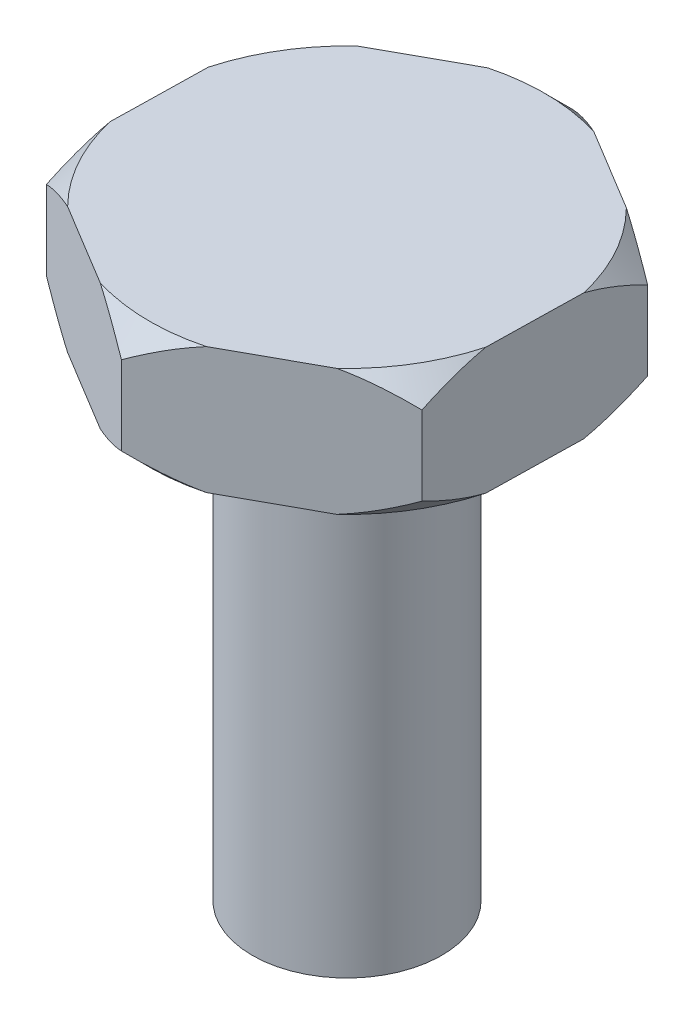
from build123d import *

# Parameters (mm, degrees)
CHAMFER1_SIZE      = 0.75
SKETCH2_OUTSIDE_W  = 21.488
SKETCH2_OUTSIDE_H  = 21.488
CUT_EXTRUDE1_DEPTH = 10


with BuildPart() as part:
    # Sketch1 → Revolve1 (revolve)
    with BuildSketch(Plane.XY):
        Polygon((0, 0), (-3, 0), (-3, 15), (-7, 15), (-7, 19), (0, 19), align=None)
    revolve(axis=Axis((0, 26.2734375, 0), (0, -1, 0)))

    # Chamfer1
    chamfer1_edges = [part.edges().sort_by_distance(p)[0] for p in [
        (7, 19, 0),
        (7, 15, 0),
    ]]
    chamfer(chamfer1_edges, length=CHAMFER1_SIZE)

    # Sketch2 outside → Cut-Extrude1 (cut)
    with BuildSketch(Plane(origin=(0, 19, 0), x_dir=(1, 0, 0), z_dir=(0, 1, 0))):
        Rectangle(SKETCH2_OUTSIDE_W, SKETCH2_OUTSIDE_H)
        Polygon((0.138817894, 6.998623407), (-5.991576715, 3.619531526), (-6.130394609, -3.379091881), (-0.138817894, -6.998623407), (5.991576715, -3.619531526), (6.130394609, 3.379091881), align=None, mode=Mode.SUBTRACT)
    extrude(amount=-CUT_EXTRUDE1_DEPTH, mode=Mode.SUBTRACT)


solid = part.part
